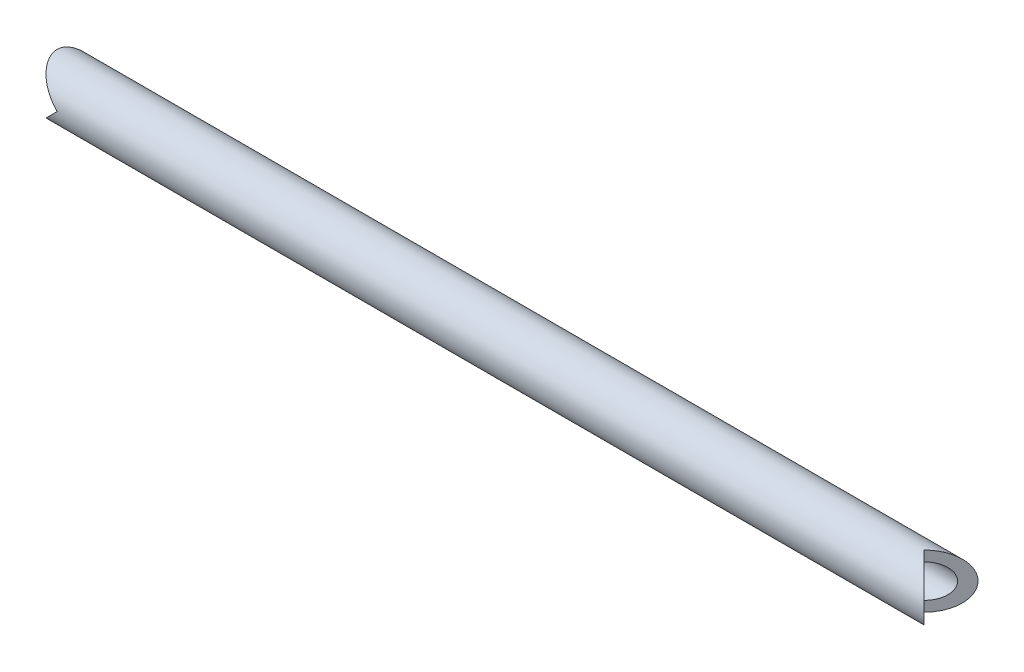
from build123d import *

# Parameters (mm, degrees)
SKETCH1_R               = 2.0066
SKETCH1_R_2             = 1.2446
BOSS_EXTRUDE1_DEPTH     = 66.675
CUT_EXTRUDE2_DEPTH      = 3.0066
CUT_EXTRUDE2_DEPTH_BACK = 3.0066
CUT_EXTRUDE3_DEPTH      = 3.0066
CUT_EXTRUDE3_DEPTH_BACK = 3.0066


with BuildPart() as part:
    # Sketch1 → Boss-Extrude1 (new body)
    with BuildSketch(Plane(origin=(0, 0, 0), x_dir=(0, 0, -1), z_dir=(1, 0, 0))):
        Circle(SKETCH1_R)
        Circle(SKETCH1_R_2, mode=Mode.SUBTRACT)
    extrude(amount=BOSS_EXTRUDE1_DEPTH)

    # Sketch3 → Cut-Extrude2 (cut, two sides)
    with BuildSketch(Plane.XY) as cut_extrude2_sk:
        Polygon((0, 2.0066), (2.0066, 0), (0, -2.0066), align=None)
    extrude(amount=CUT_EXTRUDE2_DEPTH, mode=Mode.SUBTRACT)
    extrude(cut_extrude2_sk.sketch, amount=-CUT_EXTRUDE2_DEPTH_BACK, mode=Mode.SUBTRACT)

    # Sketch4 → Cut-Extrude3 (cut, two sides)
    with BuildSketch(Plane(origin=(0, 0, 0), x_dir=(1, 0, 0), z_dir=(0, 1, 0))) as cut_extrude3_sk:
        Polygon((66.675, 2.0066), (64.6684, 0), (66.675, -2.0066), align=None)
    extrude(amount=CUT_EXTRUDE3_DEPTH, mode=Mode.SUBTRACT)
    extrude(cut_extrude3_sk.sketch, amount=-CUT_EXTRUDE3_DEPTH_BACK, mode=Mode.SUBTRACT)


solid = part.part
